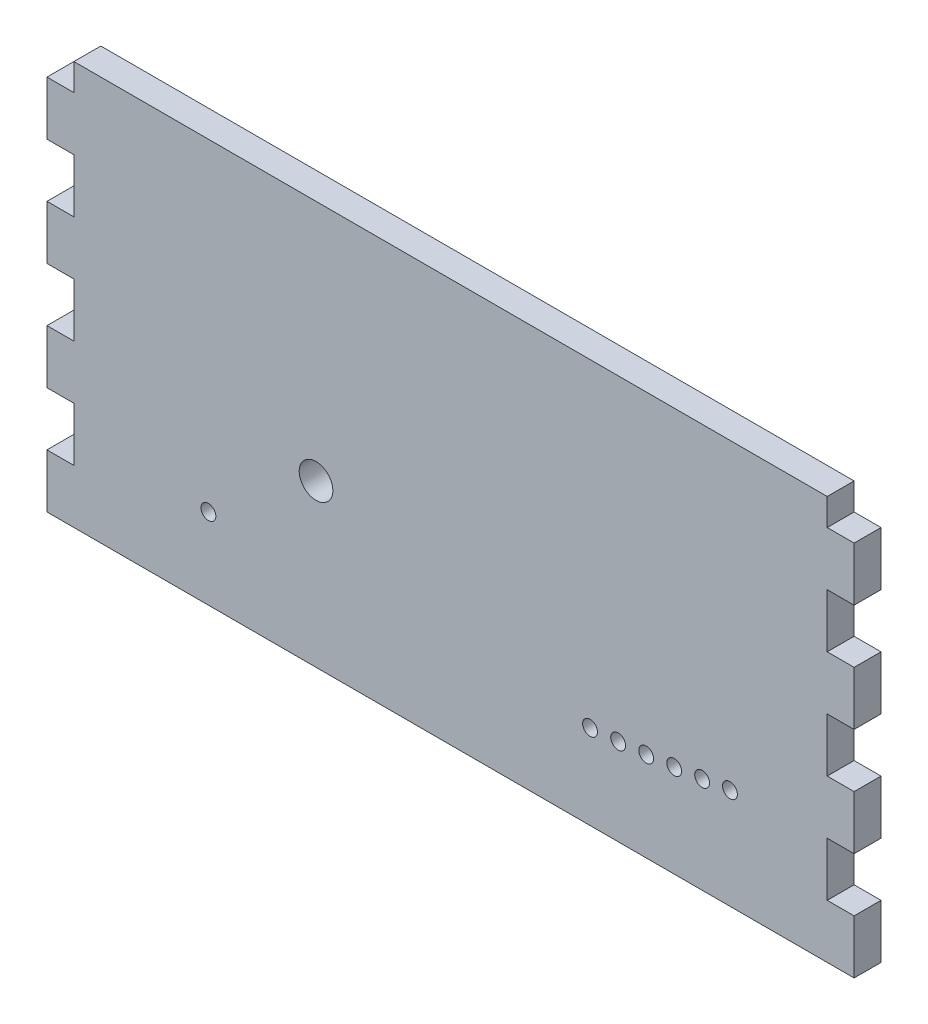
from build123d import *

# Parameters (mm, degrees)
SKETCH1_W           = 190.5
SKETCH1_H           = 95.25
BOSS_EXTRUDE1_DEPTH = 6.35
SKETCH2_R           = 3.96875
CUT_EXTRUDE1_DEPTH  = 7.35
SKETCH3_W           = 6.35
SKETCH3_H           = 12.7
CUT_EXTRUDE2_DEPTH  = 7.35
SKETCH4_W           = 6.35
SKETCH4_H           = 12.7
CUT_EXTRUDE3_DEPTH  = 7.35
LPATTERN1_COUNT     = 4
LPATTERN1_PITCH     = 25.4
SKETCH5_R           = 1.75
CUT_EXTRUDE4_DEPTH  = 7.35


with BuildPart() as part:
    # Sketch1 → Boss-Extrude1 (new body)
    with BuildSketch(Plane.XY):
        with Locations((95.25, 47.625)):
            Rectangle(SKETCH1_W, SKETCH1_H)
    extrude(amount=BOSS_EXTRUDE1_DEPTH)

    # Sketch2 → Cut-Extrude1 (cut, through all)
    with BuildSketch(Plane.XY.offset(6.35)):
        with Locations((63.5, 38.1)):
            Circle(SKETCH2_R)
    extrude(amount=-CUT_EXTRUDE1_DEPTH, mode=Mode.SUBTRACT)

    # Sketch3 → Cut-Extrude2 (cut, through all)
    with BuildSketch(Plane.XY.offset(6.35)):
        with Locations((3.175, 19.05)):
            Rectangle(SKETCH3_W, SKETCH3_H)
    cut_extrude2 = extrude(amount=-CUT_EXTRUDE2_DEPTH, mode=Mode.SUBTRACT)

    # Sketch4 → Cut-Extrude3 (cut, through all)
    with BuildSketch(Plane.XY.offset(6.35)):
        with Locations((187.325, 19.05)):
            Rectangle(SKETCH4_W, SKETCH4_H)
    cut_extrude3 = extrude(amount=-CUT_EXTRUDE3_DEPTH, mode=Mode.SUBTRACT)

    # LPattern1: Cut-Extrude2, Cut-Extrude3 ×4
    with Locations(*[(0, i * LPATTERN1_PITCH, 0) for i in range(1, LPATTERN1_COUNT)]):
        add(cut_extrude2, mode=Mode.SUBTRACT)
        add(cut_extrude3, mode=Mode.SUBTRACT)

    # Sketch5 → Cut-Extrude4 (cut, through all)
    with BuildSketch(Plane.XY.offset(6.35)):
        with Locations((38.1, 19.05)):
            Circle(SKETCH5_R)
        with Locations((128.177216497, 19.978096851)):
            Circle(SKETCH5_R)
        with Locations((134.806337987, 20.499820027)):
            Circle(SKETCH5_R)
        with Locations((141.425344505, 21.137157865)):
            Circle(SKETCH5_R)
        with Locations((148.032219837, 21.889916225)):
            Circle(SKETCH5_R)
        with Locations((154.624951466, 22.757865809)):
            Circle(SKETCH5_R)
        with Locations((161.20153118, 23.740742233)):
            Circle(SKETCH5_R)
    extrude(amount=-CUT_EXTRUDE4_DEPTH, mode=Mode.SUBTRACT)


solid = part.part
